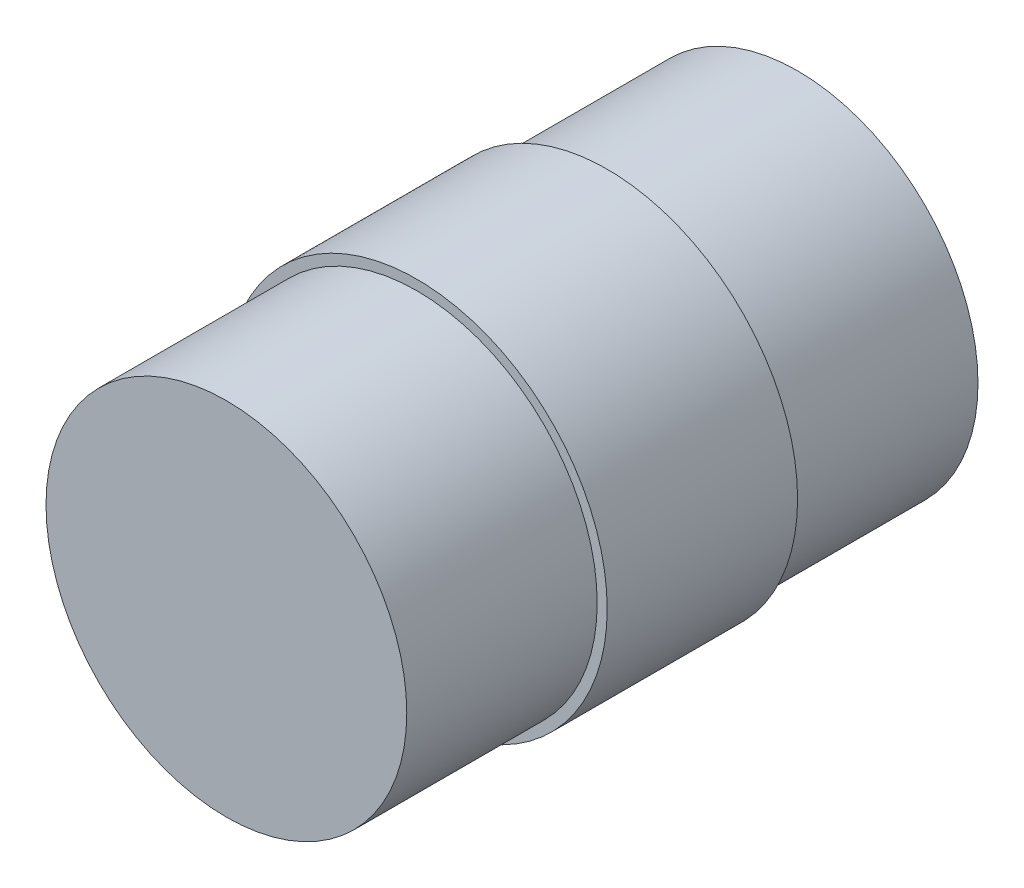
from build123d import *

# Parameters (mm, degrees)
SKETCH1_R                = 19
SKETCH1_R_2              = 18
BOSS_EXTRUDE1_DEPTH      = 19
BOSS_EXTRUDE2_DEPTH      = 38
BOSS_EXTRUDE2_DEPTH_BACK = 19
SKETCH1_3_R              = 18
SKETCH2_R                = 2.5
BOSS_EXTRUDE3_DEPTH      = 10


with BuildPart() as part:
    # Sketch1 → Boss-Extrude1 (new body)
    with BuildSketch(Plane.XY):
        Circle(SKETCH1_R)
        Circle(SKETCH1_R_2, mode=Mode.SUBTRACT)
    extrude(amount=BOSS_EXTRUDE1_DEPTH)

    # Sketch1_3 → Boss-Extrude2 (add, two sides: drawn at the far end of the back side and taken through both)
    with BuildSketch(Plane.XY.offset(-BOSS_EXTRUDE2_DEPTH_BACK)):
        Circle(SKETCH1_3_R)
    extrude(amount=BOSS_EXTRUDE2_DEPTH + BOSS_EXTRUDE2_DEPTH_BACK)

    # Sketch2 → Boss-Extrude3 (add)
    with BuildSketch(Plane(origin=(0, 0, -19), x_dir=(-1, 0, 0), z_dir=(0, 0, -1))):
        Circle(SKETCH2_R)
    extrude(amount=BOSS_EXTRUDE3_DEPTH)


solid = part.part
